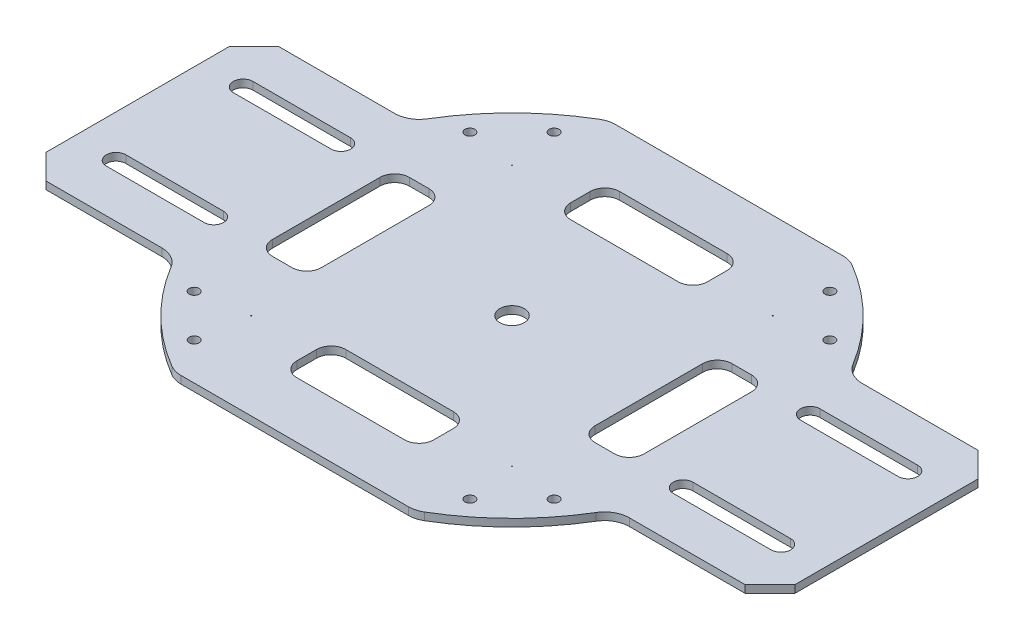
from build123d import *

# Parameters (mm, degrees)
SKETCH1_R           = 2.5
SKETCH1_R_2         = 1.016
SKETCH1_R_3         = 0.080960088
BOSS_EXTRUDE1_DEPTH = 1.55
CUT_EXTRUDE1_DEPTH  = 2.55
CUT_EXTRUDE2_DEPTH  = 2.55


with BuildPart() as part:
    # Sketch1 → Boss-Extrude1 (new body)
    with BuildSketch(Plane(origin=(0, 0, 0), x_dir=(1, 0, 0), z_dir=(0, 1, 0))):
        with BuildLine():
            Line((-23.244816627, 44.45), (23.244816627, 44.45))
            ThreePointArc((23.244816627, 44.45), (24.583514169, 44.270437622), (25.827574029, 43.744444444))
            ThreePointArc((25.827574029, 43.744444444), (35.740062311, 36.101079569), (43.482663438, 26.265909091))
            ThreePointArc((43.482663438, 26.265909091), (45.334600658, 24.468164919), (47.830929781, 23.8125))
            Line((47.830929781, 23.8125), (71.516875, 23.8125))
            Line((71.516875, 23.8125), (76.596875, 18.7325))
            Line((76.596875, 18.7325), (76.596875, -18.7325))
            Line((76.596875, -18.7325), (71.516875, -23.8125))
            Line((71.516875, -23.8125), (47.830929781, -23.8125))
            ThreePointArc((47.830929781, -23.8125), (45.334600658, -24.468164919), (43.482663438, -26.265909091))
            ThreePointArc((43.482663438, -26.265909091), (35.740062311, -36.101079569), (25.827574029, -43.744444444))
            ThreePointArc((25.827574029, -43.744444444), (24.583514169, -44.270437622), (23.244816627, -44.45))
            Line((23.244816627, -44.45), (-23.244816627, -44.45))
            ThreePointArc((-23.244816627, -44.45), (-24.583514169, -44.270437622), (-25.827574029, -43.744444444))
            ThreePointArc((-25.827574029, -43.744444444), (-35.740062311, -36.101079569), (-43.482663438, -26.265909091))
            ThreePointArc((-43.482663438, -26.265909091), (-45.334600658, -24.468164919), (-47.830929781, -23.8125))
            Line((-47.830929781, -23.8125), (-71.516875, -23.8125))
            Line((-71.516875, -23.8125), (-76.596875, -18.7325))
            Line((-76.596875, -18.7325), (-76.596875, 18.7325))
            Line((-76.596875, 18.7325), (-71.516875, 23.8125))
            Line((-71.516875, 23.8125), (-47.830929781, 23.8125))
            ThreePointArc((-47.830929781, 23.8125), (-45.334600658, 24.468164919), (-43.482663438, 26.265909091))
            ThreePointArc((-43.482663438, 26.265909091), (-35.740062311, 36.101079569), (-25.827574029, 43.744444444))
            ThreePointArc((-25.827574029, 43.744444444), (-24.583514169, 44.270437622), (-23.244816627, 44.45))
        make_face()
        Circle(SKETCH1_R, mode=Mode.SUBTRACT)
        with Locations((36.819050096, 28.19800422)):
            Circle(SKETCH1_R_2, mode=Mode.SUBTRACT)
        with Locations((28.19800422, 36.819050096)):
            Circle(SKETCH1_R_2, mode=Mode.SUBTRACT)
        with Locations((26.671582547, 26.671582547)):
            Circle(SKETCH1_R_3, mode=Mode.SUBTRACT)
        with Locations((26.671582547, -26.671582547)):
            Circle(SKETCH1_R_3, mode=Mode.SUBTRACT)
        with Locations((36.819050096, -28.19800422)):
            Circle(SKETCH1_R_2, mode=Mode.SUBTRACT)
        with Locations((28.19800422, -36.819050096)):
            Circle(SKETCH1_R_2, mode=Mode.SUBTRACT)
        with Locations((-26.671582547, -26.671582547)):
            Circle(SKETCH1_R_3, mode=Mode.SUBTRACT)
        with Locations((-28.19800422, -36.819050096)):
            Circle(SKETCH1_R_2, mode=Mode.SUBTRACT)
        with Locations((-36.819050096, -28.19800422)):
            Circle(SKETCH1_R_2, mode=Mode.SUBTRACT)
        with Locations((-26.671582547, 26.671582547)):
            Circle(SKETCH1_R_3, mode=Mode.SUBTRACT)
        with Locations((-36.819050096, 28.19800422)):
            Circle(SKETCH1_R_2, mode=Mode.SUBTRACT)
        with Locations((-28.19800422, 36.819050096)):
            Circle(SKETCH1_R_2, mode=Mode.SUBTRACT)
    extrude(amount=BOSS_EXTRUDE1_DEPTH)

    # Sketch2 → Cut-Extrude1 (cut, through all)
    with BuildSketch(Plane(origin=(0, 1.55, 0), x_dir=(1, 0, 0), z_dir=(0, 1, 0))):
        with BuildLine():
            Line((48, 15), (68, 15))
            ThreePointArc((68, 15), (70, 13), (68, 11))
            Line((68, 11), (48, 11))
            ThreePointArc((48, 11), (46, 13), (48, 15))
        make_face()
        with BuildLine():
            Line((48, -15), (68, -15))
            ThreePointArc((68, -15), (70, -13), (68, -11))
            Line((68, -11), (48, -11))
            ThreePointArc((48, -11), (46, -13), (48, -15))
        make_face()
        with BuildLine():
            Line((-48, 15), (-68, 15))
            ThreePointArc((-68, 15), (-70, 13), (-68, 11))
            Line((-68, 11), (-48, 11))
            ThreePointArc((-48, 11), (-46, 13), (-48, 15))
        make_face()
        with BuildLine():
            Line((-48, -15), (-68, -15))
            ThreePointArc((-68, -15), (-70, -13), (-68, -11))
            Line((-68, -11), (-48, -11))
            ThreePointArc((-48, -11), (-46, -13), (-48, -15))
        make_face()
    extrude(amount=-CUT_EXTRUDE1_DEPTH, mode=Mode.SUBTRACT)

    # Sketch3 → Cut-Extrude2 (cut, through all)
    with BuildSketch(Plane(origin=(0, 1.55, 0), x_dir=(1, 0, 0), z_dir=(0, 1, 0))):
        with BuildLine():
            Line((-11, 33), (11, 33))
            ThreePointArc((11, 33), (13.121320344, 32.121320344), (14, 30))
            Line((14, 30), (14, 26))
            ThreePointArc((14, 26), (13.121320344, 23.878679656), (11, 23))
            Line((11, 23), (-11, 23))
            ThreePointArc((-11, 23), (-13.121320344, 23.878679656), (-14, 26))
            Line((-14, 26), (-14, 30))
            ThreePointArc((-14, 30), (-13.121320344, 32.121320344), (-11, 33))
        make_face()
        with BuildLine():
            Line((14, -30), (14, -26))
            ThreePointArc((14, -26), (13.121320344, -23.878679656), (11, -23))
            Line((11, -23), (-11, -23))
            ThreePointArc((-11, -23), (-13.121320344, -23.878679656), (-14, -26))
            Line((-14, -26), (-14, -30))
            ThreePointArc((-14, -30), (-13.121320344, -32.121320344), (-11, -33))
            Line((-11, -33), (11, -33))
            ThreePointArc((11, -33), (13.121320344, -32.121320344), (14, -30))
        make_face()
        with BuildLine():
            Line((31, 14), (35, 14))
            ThreePointArc((35, 14), (37.121320344, 13.121320344), (38, 11))
            Line((38, 11), (38, -11))
            ThreePointArc((38, -11), (37.121320344, -13.121320344), (35, -14))
            Line((35, -14), (31, -14))
            ThreePointArc((31, -14), (28.878679656, -13.121320344), (28, -11))
            Line((28, -11), (28, 11))
            ThreePointArc((28, 11), (28.878679656, 13.121320344), (31, 14))
        make_face()
        with BuildLine():
            Line((-38, 11), (-38, -11))
            ThreePointArc((-38, -11), (-37.121320344, -13.121320344), (-35, -14))
            Line((-35, -14), (-31, -14))
            ThreePointArc((-31, -14), (-28.878679656, -13.121320344), (-28, -11))
            Line((-28, -11), (-28, 11))
            ThreePointArc((-28, 11), (-28.878679656, 13.121320344), (-31, 14))
            Line((-31, 14), (-35, 14))
            ThreePointArc((-35, 14), (-37.121320344, 13.121320344), (-38, 11))
        make_face()
    extrude(amount=-CUT_EXTRUDE2_DEPTH, mode=Mode.SUBTRACT)


solid = part.part
